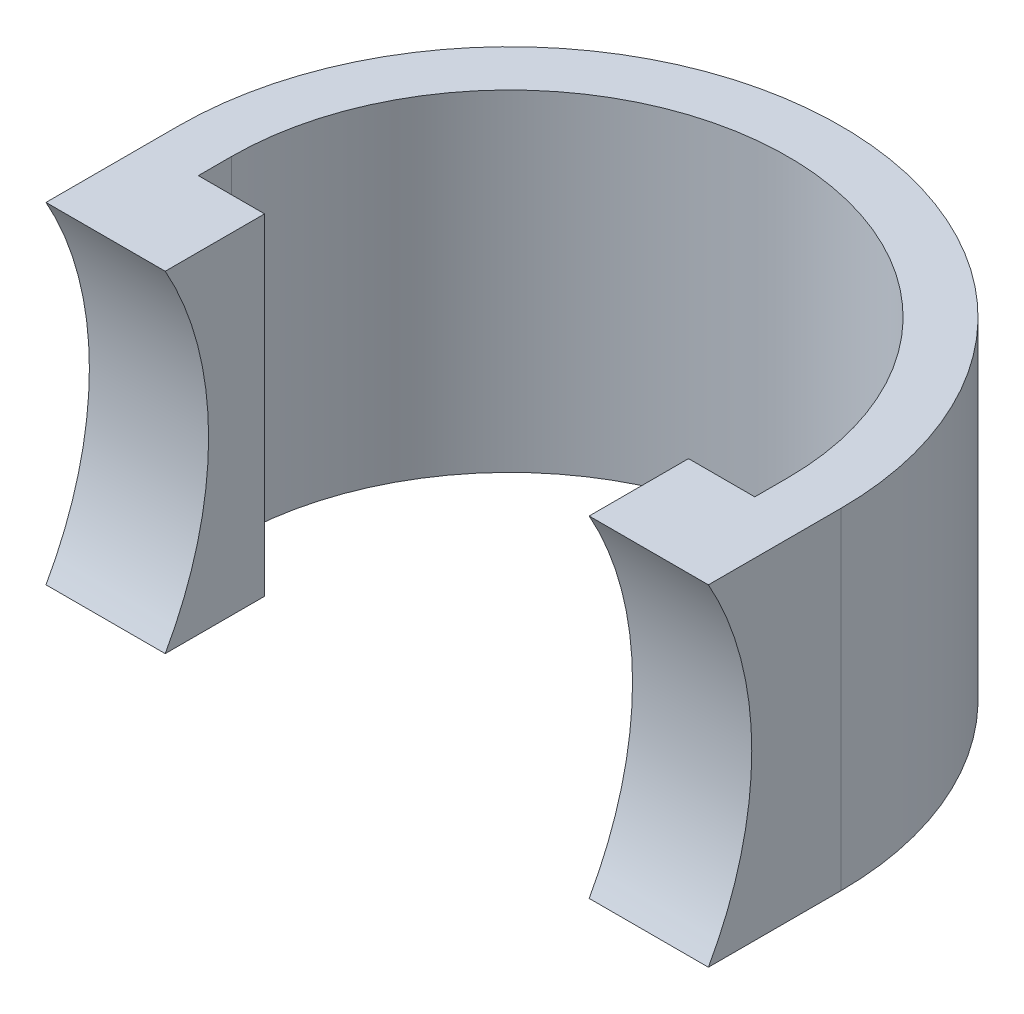
from build123d import *

# Parameters (mm, degrees)
SKETCH1_W           = 100
SKETCH1_H           = 50
BOSS_EXTRUDE1_DEPTH = 100
SKETCH2_R           = 51
CUT_EXTRUDE1_DEPTH  = 100
CUT_EXTRUDE2_DEPTH  = 100


with BuildPart() as part:
    # Sketch1 → Boss-Extrude1 (new body)
    with BuildSketch(Plane.XY):
        with Locations((14.926931106, -10.177453027)):
            Rectangle(SKETCH1_W, SKETCH1_H)
    extrude(amount=BOSS_EXTRUDE1_DEPTH)

    # Sketch2 → Cut-Extrude1 (cut)
    with BuildSketch(Plane.ZY.offset(35.073068894)):
        with Locations((144.452221542, -10.177453027)):
            Circle(SKETCH2_R)
    extrude(amount=-CUT_EXTRUDE1_DEPTH, mode=Mode.SUBTRACT)

    # Sketch3 → Cut-Extrude2 (cut)
    with BuildSketch(Plane.XZ.offset(35.177453027)):
        with BuildLine():
            Line((-35.073068894, 80), (-35.073068894, 0))
            Line((-35.073068894, 0), (64.926931106, 0))
            Line((64.926931106, 0), (64.926931106, 80))
            ThreePointArc((64.926931106, 80), (14.926931106, 30), (-35.073068894, 80))
        make_face()
        with BuildLine():
            Line((-27.073068894, 85), (-17.073068894, 85))
            Line((-17.073068894, 85), (-17.073068894, 100))
            Line((-17.073068894, 100), (46.926931106, 100))
            Line((46.926931106, 100), (46.926931106, 85))
            Line((46.926931106, 85), (56.926931106, 85))
            Line((56.926931106, 85), (56.926931106, 80))
            ThreePointArc((56.926931106, 80), (14.926931106, 38), (-27.073068894, 80))
            Line((-27.073068894, 80), (-27.073068894, 85))
        make_face()
    extrude(amount=-CUT_EXTRUDE2_DEPTH, mode=Mode.SUBTRACT)


solid = part.part
